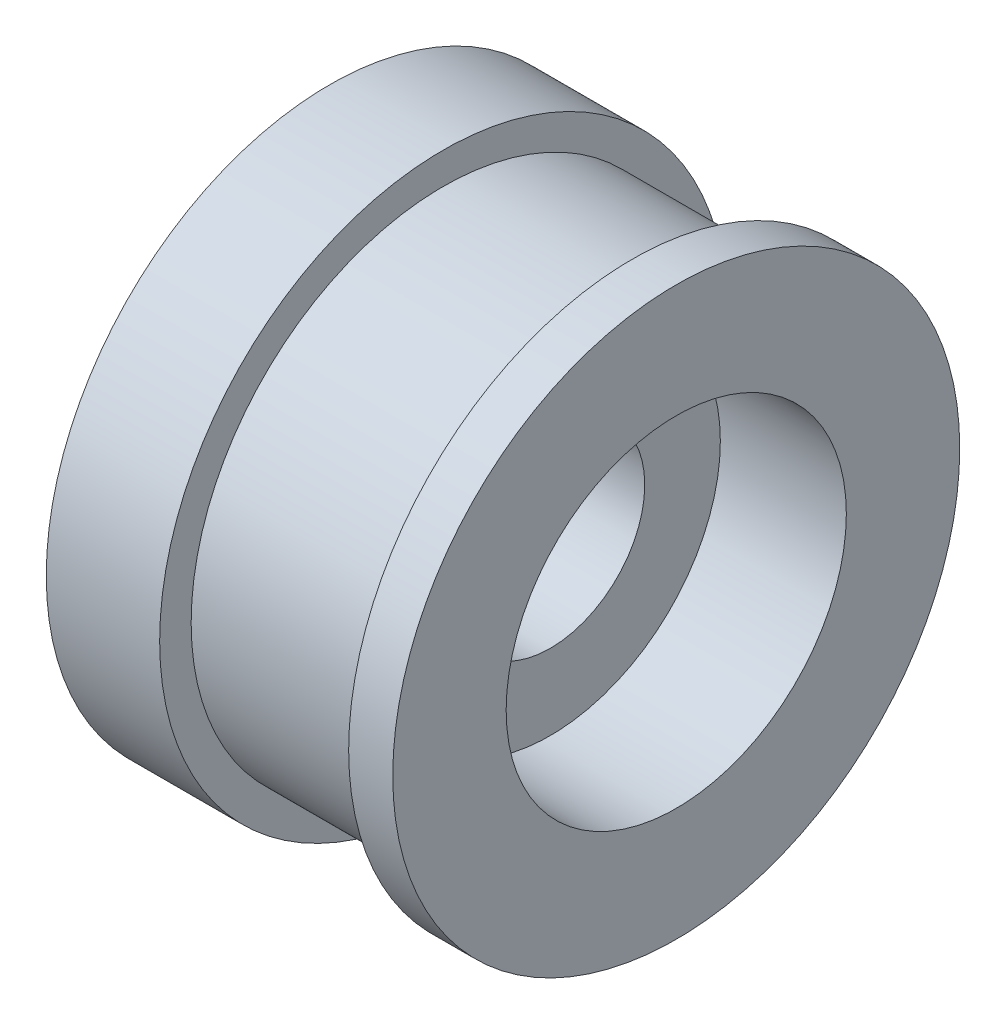
from build123d import *

# Parameters (mm, degrees)
SKETCH2_R          = 1.5
CUT_EXTRUDE1_DEPTH = 10
SKETCH3_R          = 2.7
CUT_EXTRUDE2_DEPTH = 2


with BuildPart() as part:
    # Sketch1 → Revolve1 (revolve)
    with BuildSketch(Plane(origin=(0, 0, 0), x_dir=(1, 0, 0), z_dir=(0, 1, 0))):
        Polygon((0, 0), (0, 4.5), (1.8, 4.5), (1.8, 4), (4.8, 4), (4.8, 4.5), (5.5, 4.5), (5.5, 0), align=None)
    revolve(axis=Axis((-92.33576491, 0, 0), (1, 0, 0)))

    # Sketch2 → Cut-Extrude1 (cut)
    with BuildSketch(Plane.ZY):
        Circle(SKETCH2_R)
    extrude(amount=-CUT_EXTRUDE1_DEPTH, mode=Mode.SUBTRACT)

    # Sketch3 → Cut-Extrude2 (cut)
    with BuildSketch(Plane(origin=(5.5, 0, 0), x_dir=(0, 0, -1), z_dir=(1, 0, 0))):
        Circle(SKETCH3_R)
    extrude(amount=-CUT_EXTRUDE2_DEPTH, mode=Mode.SUBTRACT)


solid = part.part
